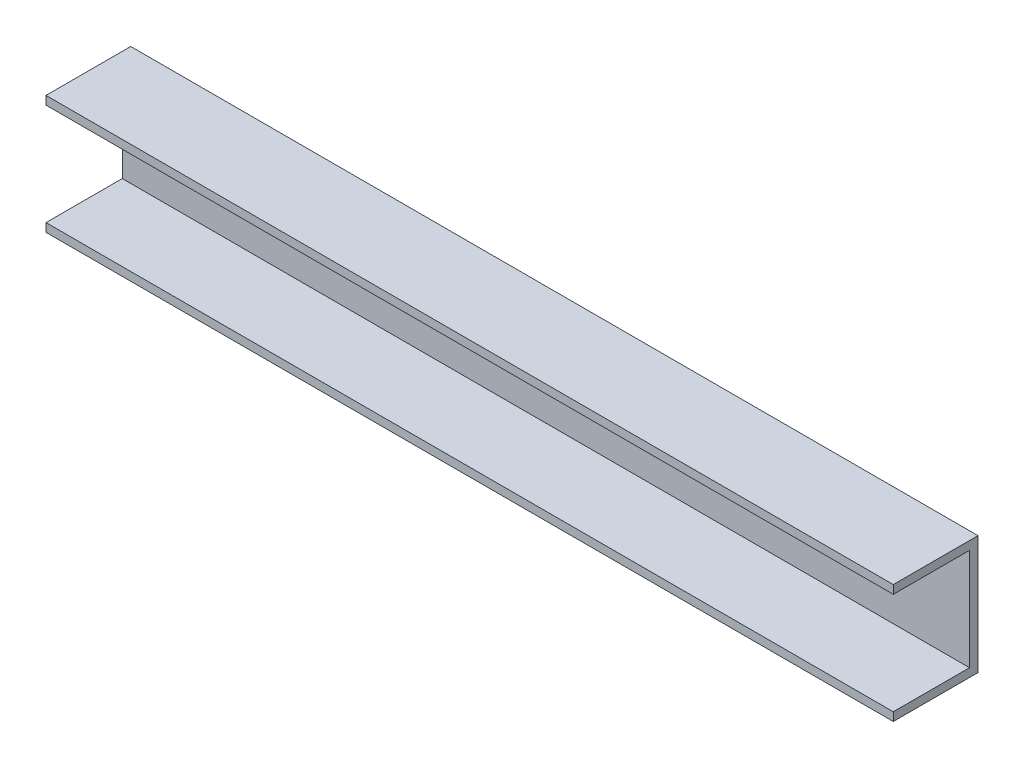
from build123d import *

# Parameters (mm, degrees)
BOSS_EXTRUDE1_DEPTH = 250


with BuildPart() as part:
    # Sketch1 → Boss-Extrude1 (new body, symmetric)
    with BuildSketch(Plane(origin=(0, 0, 0), x_dir=(0, 0, -1), z_dir=(1, 0, 0))):
        Polygon((-33.959336145, 53.010184438), (16.040663855, 53.010184438), (16.040663855, -16.989815562), (-33.959336145, -16.989815562), (-33.959336145, -11.989815562), (11.040663855, -11.989815562), (11.040663855, 48.010184438), (-33.959336145, 48.010184438), align=None)
    extrude(amount=BOSS_EXTRUDE1_DEPTH, both=True)


solid = part.part
